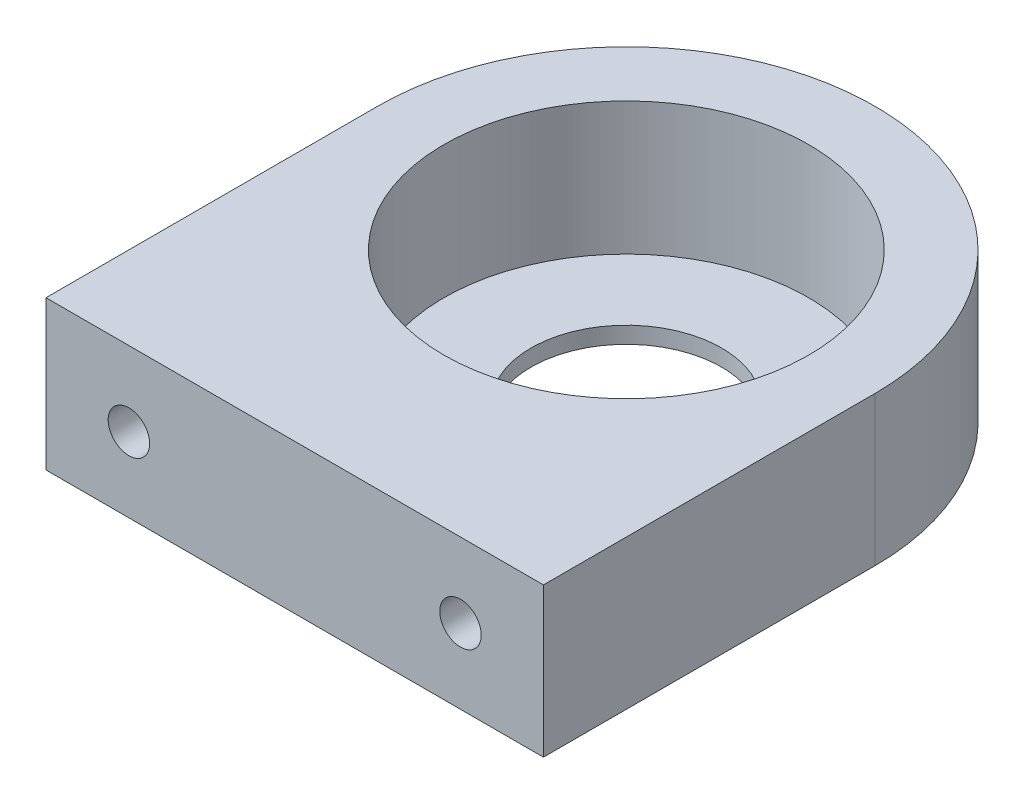
from build123d import *

# Parameters (mm, degrees)
SKETCH1_R           = 11
SKETCH1_R_2         = 5.75
BOSS_EXTRUDE1_DEPTH = 9
SKETCH2_R           = 11
CUT_EXTRUDE1_DEPTH  = 8
SKETCH8_R           = 1.25
CUT_EXTRUDE2_DEPTH  = 10


with BuildPart() as part:
    # Sketch1 → Boss-Extrude1 (new body)
    with BuildSketch(Plane(origin=(0, 0, 0), x_dir=(1, 0, 0), z_dir=(0, 1, 0))):
        with BuildLine():
            Line((30, 0), (30, 20))
            ThreePointArc((30, 20), (15, 35), (0, 20))
            Line((0, 20), (0, 0))
            Line((0, 0), (30, 0))
        make_face()
        with Locations((15, 20)):
            Circle(SKETCH1_R, mode=Mode.SUBTRACT)
        with Locations((15, 20)):
            Circle(SKETCH1_R)
        with Locations((15, 20)):
            Circle(SKETCH1_R_2, mode=Mode.SUBTRACT)
    extrude(amount=BOSS_EXTRUDE1_DEPTH)

    # Sketch2 → Cut-Extrude1 (cut)
    with BuildSketch(Plane(origin=(0, 9, 0), x_dir=(1, 0, 0), z_dir=(0, 1, 0))):
        with Locations((15, 20)):
            Circle(SKETCH2_R)
    extrude(amount=-CUT_EXTRUDE1_DEPTH, mode=Mode.SUBTRACT)

    # Sketch8 → Cut-Extrude2 (cut)
    with BuildSketch(Plane.XY):
        with Locations((25, 4.5)):
            Circle(SKETCH8_R)
        with Locations((5, 4.5)):
            Circle(SKETCH8_R)
    extrude(amount=-CUT_EXTRUDE2_DEPTH, mode=Mode.SUBTRACT)


solid = part.part
